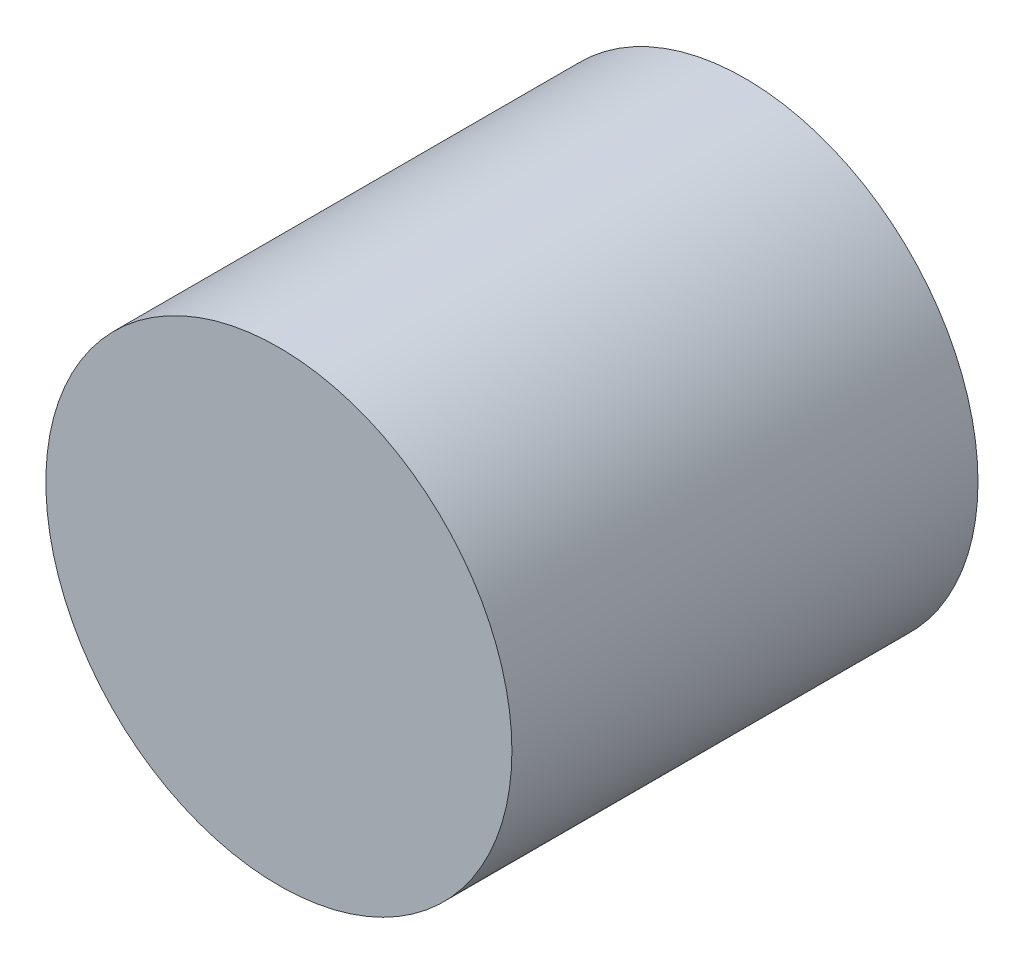
from build123d import *

# Parameters (mm, degrees)
SKETCH1_R           = 1.75
BOSS_EXTRUDE1_DEPTH = 3.5


with BuildPart() as part:
    # Sketch1 → Boss-Extrude1 (new body)
    with BuildSketch(Plane.XY):
        Circle(SKETCH1_R)
    extrude(amount=BOSS_EXTRUDE1_DEPTH)


solid = part.part
